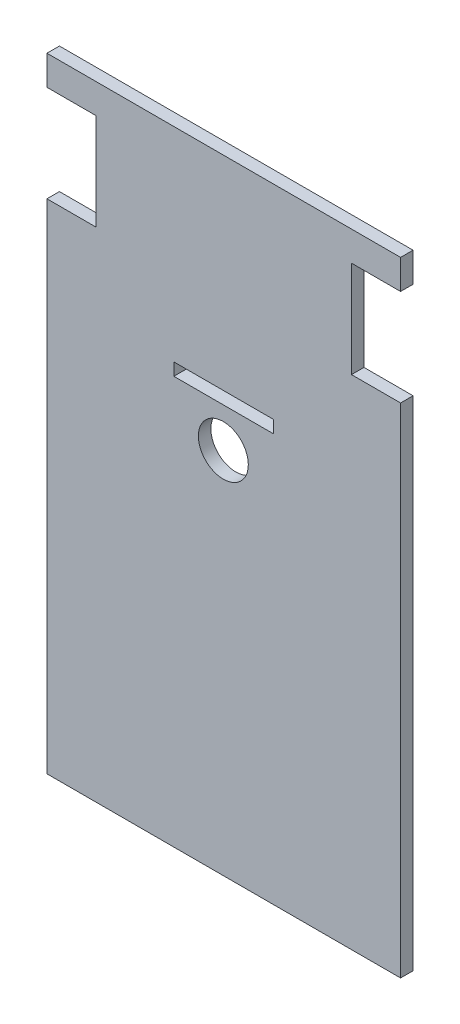
from build123d import *

# Parameters (mm, degrees)
MODEL_R                 = 6
MODEL_W                 = 24
MODEL_H                 = 3
SALIENTE_EXTRUIR1_DEPTH = 3


with BuildPart() as part:
    # Model → Saliente-Extruir1 (new body)
    with BuildSketch(Plane.XY):
        Polygon((16.40298836, 92.600311204), (16.40298836, 85.500311204), (28.20298836, 85.500311204), (28.20298836, 62.300311204), (16.40298836, 62.300311204), (16.40298836, -57.399688796), (101.40298836, -57.399688796), (101.40298836, 62.300311204), (89.60298836, 62.300311204), (89.60298836, 85.500311204), (101.40298836, 85.500311204), (101.40298836, 92.600311204), align=None)
        with Locations((58.802292593, 31.129874196)):
            Circle(MODEL_R, mode=Mode.SUBTRACT)
        with Locations((58.90298836, 42.100311204)):
            Rectangle(MODEL_W, MODEL_H, mode=Mode.SUBTRACT)
    extrude(amount=SALIENTE_EXTRUIR1_DEPTH)


solid = part.part
